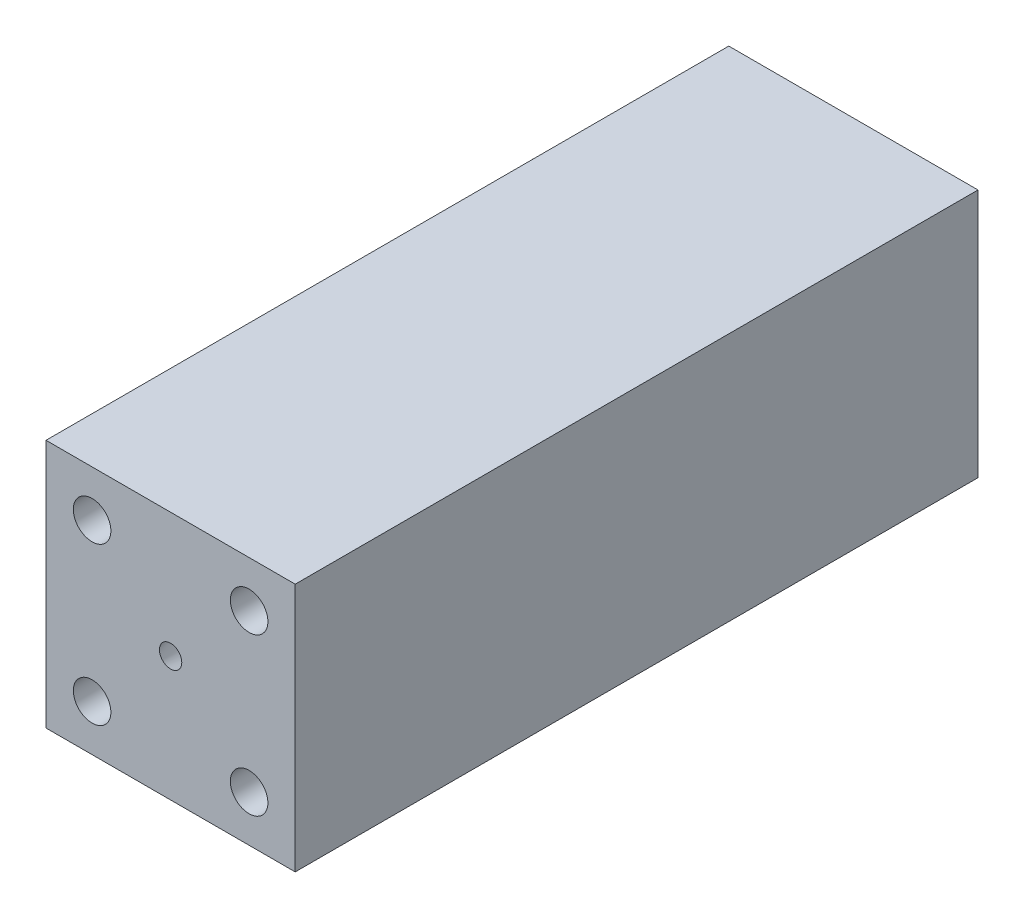
from build123d import *

# Parameters (mm, degrees)
SKETCH1_W               = 46.355
SKETCH1_H               = 46.355
BOSS_EXTRUDE1_DEPTH     = 127
SKETCH2_R               = 1.397
CUT_EXTRUDE1_DEPTH      = 128
SKETCH4_R               = 3.4925
CUT_EXTRUDE3_DEPTH      = 128
MIRROR2_COPY_1_SKETCH_R = 3.4925
MIRROR2_COPY_1_DEPTH    = 128


with BuildPart() as part:
    # Sketch1 → Boss-Extrude1 (new body)
    with BuildSketch(Plane.XY):
        Rectangle(SKETCH1_W, SKETCH1_H)
    extrude(amount=BOSS_EXTRUDE1_DEPTH)

    # Sketch2 → Cut-Extrude1 (cut, through all)
    with BuildSketch(Plane.XY.offset(127)):
        Circle(SKETCH2_R)
    extrude(amount=-CUT_EXTRUDE1_DEPTH, mode=Mode.SUBTRACT)

    # Sketch4 → Cut-Extrude3 (cut, through all)
    with BuildSketch(Plane.XY.offset(127)):
        with Locations((14.601896453, 14.601896453)):
            Circle(SKETCH4_R)
    cut_extrude3 = extrude(amount=-CUT_EXTRUDE3_DEPTH, mode=Mode.SUBTRACT)

    # Mirror1: Cut-Extrude3 across plane
    add(cut_extrude3.mirror(Plane.ZX), mode=Mode.SUBTRACT)

    # Mirror2: Cut-Extrude3 across plane
    add(cut_extrude3.mirror(Plane(origin=(0, 0, 0), x_dir=(0, 0, 1), z_dir=(1, 0, 0))), mode=Mode.SUBTRACT)

    # Mirror2 copy 1 sketch → Mirror2 copy 1 (cut, through all)
    with BuildSketch(Plane(origin=(0, 0, 127), x_dir=(-1, 0, 0), z_dir=(0, 0, 1))):
        with Locations((14.601896453, 14.601896453)):
            Circle(MIRROR2_COPY_1_SKETCH_R)
    extrude(amount=-MIRROR2_COPY_1_DEPTH, mode=Mode.SUBTRACT)

    # Sketch5 → Cut-Revolve1 (revolve, cut)
    with BuildSketch(Plane(origin=(0, 0, 0), x_dir=(0, 0, -1), z_dir=(1, 0, 0))):
        Polygon((0, 14.601896453), (-44.712215564, 14.601896453), (-70.584924633, 2.078286108), (-70.584924633, 13.343436946), (-87.296961591, 13.343436946), (-127, 2.078286108), (-127, 0), (0, 0), align=None)
    revolve(axis=Axis((0, 0, 127), (0, 0, -1)), mode=Mode.SUBTRACT)


solid = part.part
